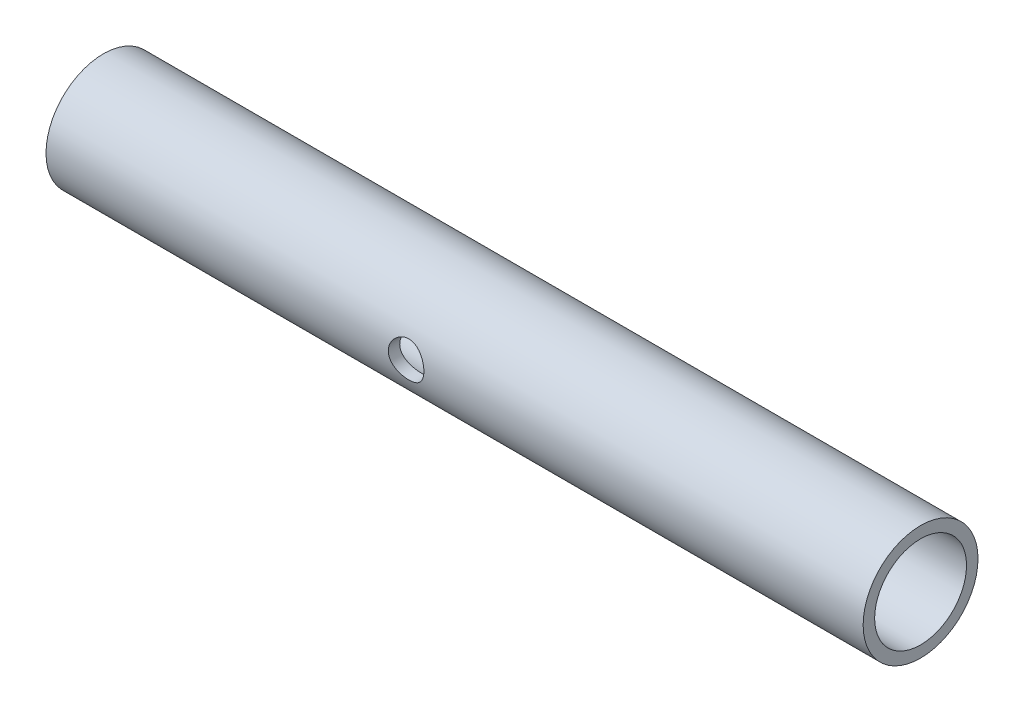
from build123d import *

# Parameters (mm, degrees)
SKETCH_1_R              = 10
SKETCH_1_R_2            = 8
EXTRUDE_1_DEPTH         = 107
SKETCH_2_R              = 10
SKETCH_2_R_2            = 8
EXTRUDE_2_DEPTH         = 35.3
SKETCH2_R               = 3.1
CUT_EXTRUDE2_DEPTH      = 11
CUT_EXTRUDE2_DEPTH_BACK = 11


with BuildPart() as part:
    # 草图1 → 凸台-拉伸1 (new body)
    with BuildSketch(Plane(origin=(0, 0, 0), x_dir=(0, 0, -1), z_dir=(1, 0, 0))):
        Circle(SKETCH_1_R)
        Circle(SKETCH_1_R_2, mode=Mode.SUBTRACT)
    extrude(amount=EXTRUDE_1_DEPTH)

    # 草图2 → 凸台-拉伸2 (add)
    with BuildSketch(Plane.ZY):
        Circle(SKETCH_2_R)
        Circle(SKETCH_2_R_2, mode=Mode.SUBTRACT)
    extrude(amount=EXTRUDE_2_DEPTH)

    # Sketch2 → Cut-Extrude2 (cut, two sides)
    with BuildSketch(Plane.XY) as cut_extrude2_sk:
        with Locations((27.4, 0)):
            Circle(SKETCH2_R)
    extrude(amount=CUT_EXTRUDE2_DEPTH, mode=Mode.SUBTRACT)
    extrude(cut_extrude2_sk.sketch, amount=-CUT_EXTRUDE2_DEPTH_BACK, mode=Mode.SUBTRACT)


solid = part.part
